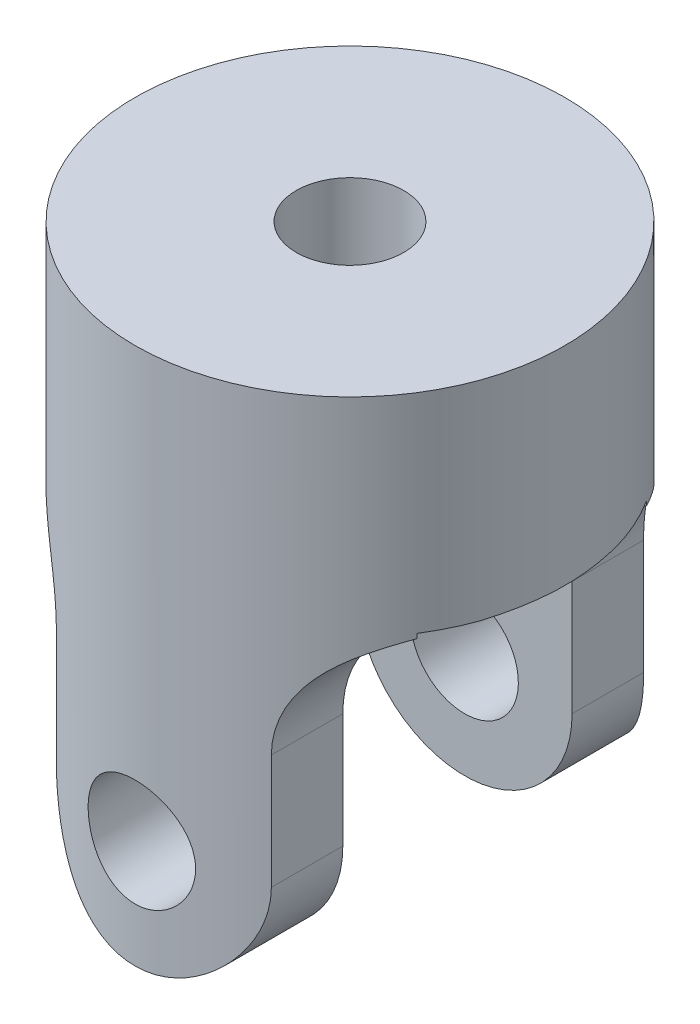
from build123d import *

# Parameters (mm, degrees)
SKETCH1_R               = 19.05
BASE_EXTRUDE_DEPTH      = 47.625
CUT_EXTRUDE1_DEPTH      = 55.716959208
CUT_EXTRUDE1_DEPTH_BACK = 55.716959208
CUT_EXTRUDE5_DEPTH      = 55.716959365
CUT_EXTRUDE5_DEPTH_BACK = 55.716959365
CUT_EXTRUDE6_DEPTH      = 55.716959365
CUT_EXTRUDE6_DEPTH_BACK = 55.716959365
SKETCH11_R              = 4.7625
SKETCH12_R              = 4.7625
CUT_EXTRUDE7_DEPTH      = 55.716959372


with BuildPart() as part:
    # Sketch1 → Base-Extrude (new body)
    with BuildSketch(Plane(origin=(0, 0, 0), x_dir=(-1, 0, 0), z_dir=(0, 1, 0))):
        Circle(SKETCH1_R)
    extrude(amount=BASE_EXTRUDE_DEPTH)

    # Sketch2 → Cut-Extrude1 (cut, two sides: drawn at the far end of the back side and taken through both)
    with BuildSketch(Plane.XY.offset(-CUT_EXTRUDE1_DEPTH_BACK)):
        with BuildLine():
            Line((-19.05, -131.979516723), (-19.05, 0))
            Line((-19.05, 0), (-19.05, 29.21))
            ThreePointArc((-19.05, 29.21), (-12.314807909, 26.420192091), (-9.525, 19.685))
            Line((-9.525, 19.685), (-9.525, 9.525))
            ThreePointArc((-9.525, 9.525), (0, 0), (9.525, 9.525))
            Line((9.525, 9.525), (9.525, 19.685))
            ThreePointArc((9.525, 19.685), (12.314807909, 26.420192091), (19.05, 29.21))
            Line((19.05, 29.21), (19.05, 0))
            Line((19.05, 0), (19.05, -131.979516723))
            Line((19.05, -131.979516723), (19.05, -395.938550169))
            Line((19.05, -395.938550169), (-19.05, -395.938550169))
            Line((-19.05, -395.938550169), (-19.05, -131.979516723))
        make_face()
    extrude(amount=CUT_EXTRUDE1_DEPTH + CUT_EXTRUDE1_DEPTH_BACK, mode=Mode.SUBTRACT)

    # Sketch8 → Cut-Extrude5 (cut, two sides: drawn at the far end of the back side and taken through both)
    with BuildSketch(Plane(origin=(0, 0, 0), x_dir=(0, 0, -1), z_dir=(1, 0, 0)).offset(-CUT_EXTRUDE5_DEPTH_BACK)):
        Polygon((-10.16, -121.738350451), (-10.16, 0), (-10.16, 29.145238826), (10.16, 29.145238826), (10.16, 0), (10.16, -121.738350451), (10.16, -365.215051352), (-10.16, -365.215051352), align=None)
    extrude(amount=CUT_EXTRUDE5_DEPTH + CUT_EXTRUDE5_DEPTH_BACK, mode=Mode.SUBTRACT)

    # Sketch11 → Cut-Extrude6 (cut, two sides: drawn at the far end of the back side and taken through both)
    with BuildSketch(Plane.XY.offset(-CUT_EXTRUDE6_DEPTH_BACK)):
        with Locations((0, 9.525)):
            Circle(SKETCH11_R)
    extrude(amount=CUT_EXTRUDE6_DEPTH + CUT_EXTRUDE6_DEPTH_BACK, mode=Mode.SUBTRACT)

    # Sketch12 → Cut-Extrude7 (cut, through all)
    with BuildSketch(Plane(origin=(0, 47.625, 0), x_dir=(-1, 0, 0), z_dir=(0, 1, 0))):
        Circle(SKETCH12_R)
    extrude(amount=-CUT_EXTRUDE7_DEPTH, mode=Mode.SUBTRACT)


solid = part.part
